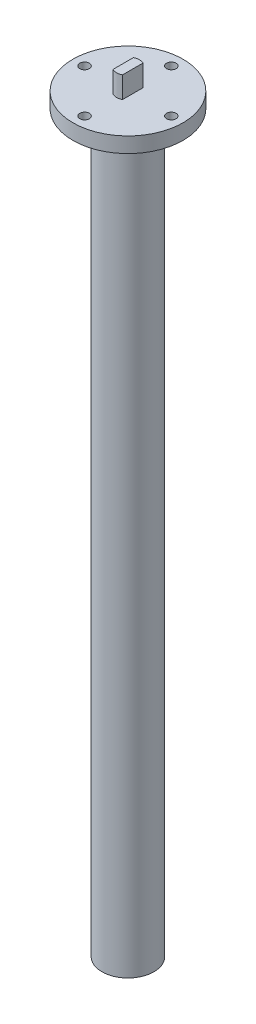
from build123d import *

# Parameters (mm, degrees)
SKETCH1_R                           = 22.86
BOSS_EXTRUDE1_DEPTH                 = 6.35
BOSS_EXTRUDE2_DEPTH                 = 8.89
SKETCH3_R                           = 10.795
BOSS_EXTRUDE3_DEPTH                 = 304.8
CHAMFER1_SIZE                       = 3.81
F_5_32_0_15625_DIAMETER_HOLE1_D     = 3.96875
F_5_32_0_15625_DIAMETER_HOLE1_DEPTH = 6.351
CIRPATTERN1_COUNT                   = 4


with BuildPart() as part:
    # Sketch1 → Boss-Extrude1 (new body)
    with BuildSketch(Plane(origin=(0, 0, 0), x_dir=(1, 0, 0), z_dir=(0, 1, 0))):
        Circle(SKETCH1_R)
    extrude(amount=BOSS_EXTRUDE1_DEPTH)

    # Sketch2 → Boss-Extrude2 (add)
    with BuildSketch(Plane(origin=(0, 6.35, 0), x_dir=(1, 0, 0), z_dir=(0, 1, 0))):
        with BuildLine():
            Line((1.9685, -4.266803107), (1.9685, 4.266803107))
            ThreePointArc((1.9685, 4.266803107), (0, 4.699), (-1.9685, 4.266803107))
            Line((-1.9685, 4.266803107), (-1.9685, -4.266803107))
            ThreePointArc((-1.9685, -4.266803107), (0, -4.699), (1.9685, -4.266803107))
        make_face()
    extrude(amount=BOSS_EXTRUDE2_DEPTH)

    # Sketch3 → Boss-Extrude3 (add)
    with BuildSketch(Plane.XZ):
        Circle(SKETCH3_R)
    extrude(amount=BOSS_EXTRUDE3_DEPTH)

    # Chamfer1
    chamfer1_edges = [part.edges().sort_by_distance(p)[0] for p in [
        (-10.795, 0, 0),
    ]]
    chamfer(chamfer1_edges, length=CHAMFER1_SIZE)

    # 5/32 (0.15625) Diameter Hole1
    with Locations(Plane(origin=(0, 6.35, 0), x_dir=(1, 0, 0), z_dir=(0, 1, 0))):
        with Locations((0, 18)):
            f_5_32_0_15625_diameter_hole1 = Hole(F_5_32_0_15625_DIAMETER_HOLE1_D / 2, depth=F_5_32_0_15625_DIAMETER_HOLE1_DEPTH)

    # CirPattern1: 5/32 (0.15625) Diameter Hole1 ×4 about axis
    cirpattern1_axis = Axis((0, 0, 0), (0, 1, 0))
    for i in range(1, CIRPATTERN1_COUNT):
        add(f_5_32_0_15625_diameter_hole1.rotate(cirpattern1_axis, i * 360 / CIRPATTERN1_COUNT), mode=Mode.SUBTRACT)


solid = part.part
